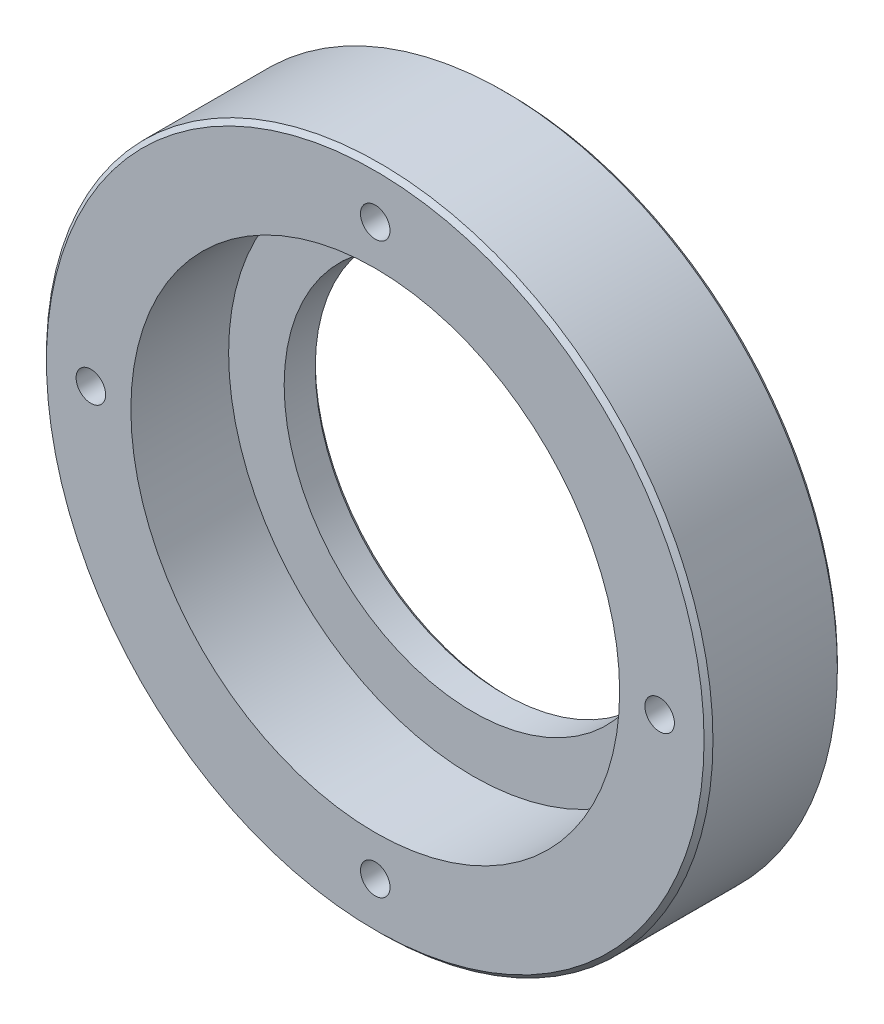
from build123d import *

# Parameters (mm, degrees)
SKETCH1_W                                = 75
SKETCH1_H                                = 30
CBORE_FOR_M80_HEX_HEAD_BOLT1_D           = 85
CBORE_FOR_M80_HEX_HEAD_BOLT1_DEPTH       = 30
CBORE_FOR_M80_HEX_HEAD_BOLT1_CBORE_D     = 110
CBORE_FOR_M80_HEX_HEAD_BOLT1_CBORE_DEPTH = 22
HOLE1_D                                  = 8.376
HOLE1_DEPTH                              = 20
HOLE1_TIP                                = 2.516404272
M6_CLEARANCE_HOLE1_D                     = 6.647
M6_CLEARANCE_HOLE1_DEPTH                 = 12
M6_CLEARANCE_HOLE1_TIP                   = 1.996960267
CHAMFER1_SIZE                            = 1


with BuildPart() as part:
    # Sketch1 → Revolve1 (revolve)
    with BuildSketch(Plane(origin=(0, 0, 0), x_dir=(1, 0, 0), z_dir=(0, 1, 0))):
        with Locations((37.5, -15)):
            Rectangle(SKETCH1_W, SKETCH1_H)
    revolve(axis=Axis((0, 0, 0), (0, 0, 1)))

    # CBORE for M80 Hex Head Bolt1
    with Locations(Plane.XY.offset(30)):
        with Locations((0, 0)):
            CounterBoreHole(CBORE_FOR_M80_HEX_HEAD_BOLT1_D / 2, CBORE_FOR_M80_HEX_HEAD_BOLT1_CBORE_D / 2, CBORE_FOR_M80_HEX_HEAD_BOLT1_CBORE_DEPTH, depth=CBORE_FOR_M80_HEX_HEAD_BOLT1_DEPTH)

    # Hole1
    with Locations(Plane(origin=(0, 0, 0), x_dir=(-1, 0, 0), z_dir=(0, 0, -1))):
        with Locations((45.254833996, 45.254833996), (-45.254833996, 45.254833996), (-45.254833996, -45.254833996), (45.254833996, -45.254833996)):
            Hole(HOLE1_D / 2, depth=HOLE1_DEPTH)
            with Locations((0, 0, -(HOLE1_DEPTH + HOLE1_TIP / 2))):  # 118° drill point
                Cone(0, HOLE1_D / 2, HOLE1_TIP, mode=Mode.SUBTRACT)

    # M6 Clearance Hole1
    with Locations(Plane.XY.offset(30)):
        with Locations((0, 64), (0, -64), (64, 0), (-64, 0)):
            Hole(M6_CLEARANCE_HOLE1_D / 2, depth=M6_CLEARANCE_HOLE1_DEPTH)
            with Locations((0, 0, -(M6_CLEARANCE_HOLE1_DEPTH + M6_CLEARANCE_HOLE1_TIP / 2))):  # 118° drill point
                Cone(0, M6_CLEARANCE_HOLE1_D / 2, M6_CLEARANCE_HOLE1_TIP, mode=Mode.SUBTRACT)

    # Chamfer1
    chamfer1_edges = [part.edges().sort_by_distance(p)[0] for p in [
        (42.5, 0, 0),
        (-75, 0, 30),
        (-75, 0, 0),
    ]]
    chamfer(chamfer1_edges, length=CHAMFER1_SIZE)


solid = part.part
